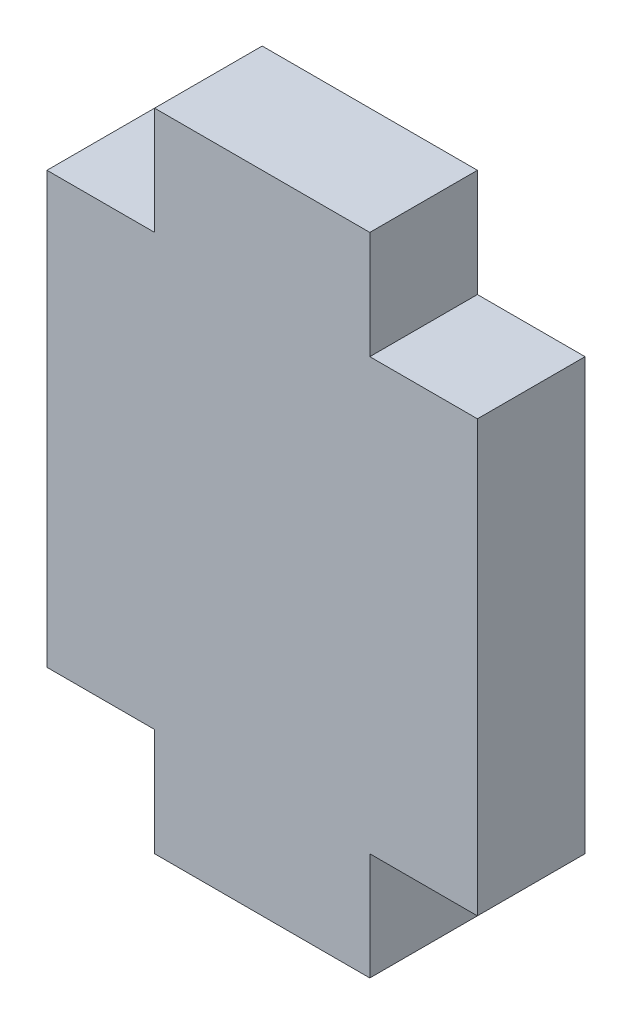
from build123d import *

# Parameters (mm, degrees)
BOSS_EXTRUDE1_DEPTH = 6.35


with BuildPart() as part:
    # Sketch1 → Boss-Extrude1 (new body)
    with BuildSketch(Plane.XY):
        Polygon((-19.05, 0), (-25.4, 0), (-25.4, 25.4), (-19.05, 25.4), (-19.05, 31.75), (-6.35, 31.75), (-6.35, 25.4), (0, 25.4), (0, 0), (-6.35, 0), (-6.35, -6.35), (-19.05, -6.35), align=None)
    extrude(amount=BOSS_EXTRUDE1_DEPTH)


solid = part.part
